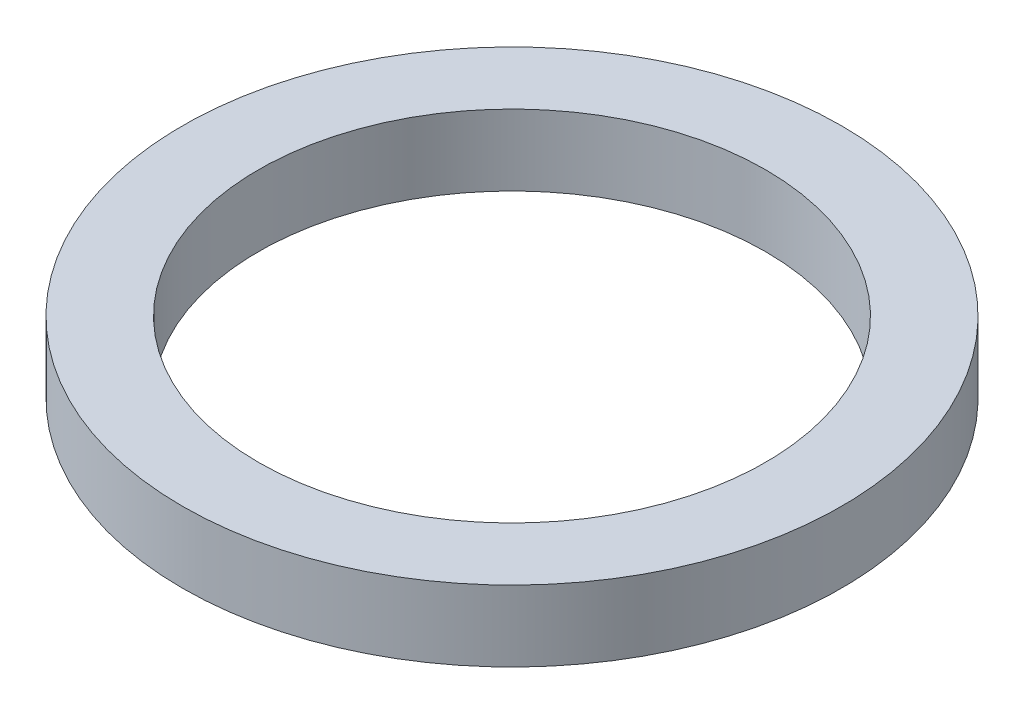
from build123d import *

# Parameters (mm, degrees)
SKETCH1_R           = 32.5
SKETCH1_R_2         = 25
BOSS_EXTRUDE1_DEPTH = 7


with BuildPart() as part:
    # Sketch1 → Boss-Extrude1 (new body)
    with BuildSketch(Plane(origin=(0, 0, 0), x_dir=(1, 0, 0), z_dir=(0, 1, 0))):
        Circle(SKETCH1_R)
        Circle(SKETCH1_R_2, mode=Mode.SUBTRACT)
    extrude(amount=BOSS_EXTRUDE1_DEPTH)


solid = part.part
